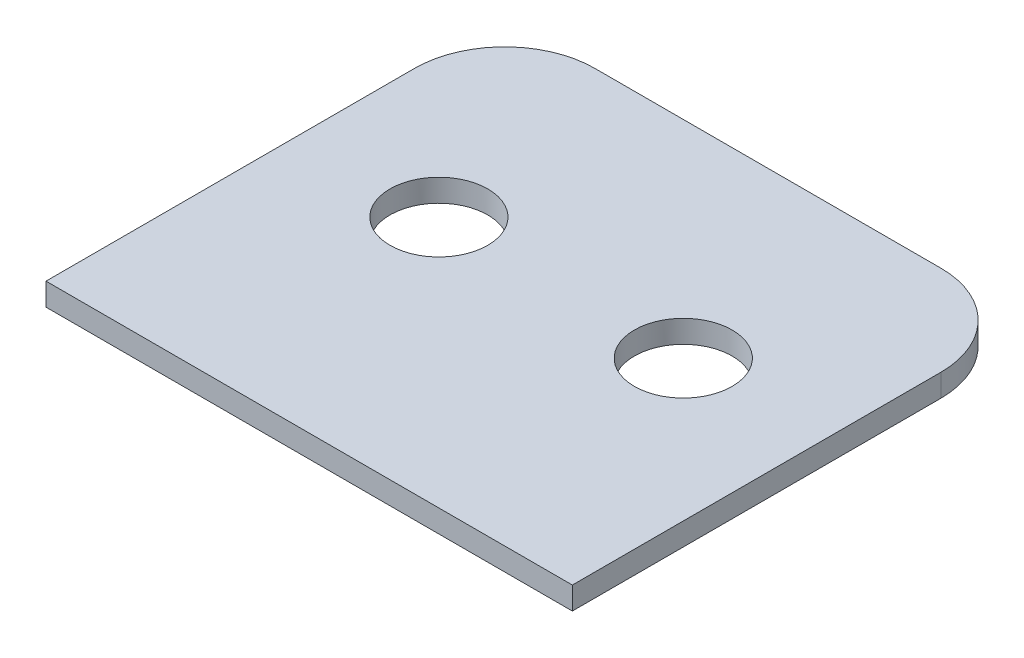
from build123d import *

# Parameters (mm, degrees)
SKETCH1_W               = 70
SKETCH1_H               = 67
BOSS_EXTRUDE1_DEPTH     = 3
SKETCH5_W               = 70
SKETCH5_H               = 6
CUT_EXTRUDE4_DEPTH      = 1
CUT_EXTRUDE4_DEPTH_BACK = 4
FILLET1_R               = 12
CUT_EXTRUDE1_START      = -4
SKETCH2_R               = 6.5
CUT_EXTRUDE1_DEPTH      = 5


with BuildPart() as part:
    # Sketch1 → Boss-Extrude1 (new body)
    with BuildSketch(Plane(origin=(0, 0, 0), x_dir=(1, 0, 0), z_dir=(0, 1, 0))):
        Rectangle(SKETCH1_W, SKETCH1_H)
    extrude(amount=BOSS_EXTRUDE1_DEPTH)

    # Sketch5 → Cut-Extrude4 (cut, two sides)
    with BuildSketch(Plane(origin=(0, 3, 0), x_dir=(1, 0, 0), z_dir=(0, 1, 0))) as cut_extrude4_sk:
        with Locations((0, 30.5)):
            Rectangle(SKETCH5_W, SKETCH5_H)
    extrude(amount=CUT_EXTRUDE4_DEPTH, mode=Mode.SUBTRACT)
    extrude(cut_extrude4_sk.sketch, amount=-CUT_EXTRUDE4_DEPTH_BACK, mode=Mode.SUBTRACT)

    # Fillet1
    fillet1_edges = [part.edges().sort_by_distance(p)[0] for p in [
        (-35, 1.5, -27.5),
        (35, 1.5, -27.5),
    ]]
    fillet(fillet1_edges, radius=FILLET1_R)

    # Sketch2 → Cut-Extrude1 (cut)
    with BuildSketch(Plane(origin=(0, 3, 0), x_dir=(1, 0, 0), z_dir=(0, 1, 0)).offset(CUT_EXTRUDE1_START)):
        with Locations((-16.25, 0)):
            Circle(SKETCH2_R)
    cut_extrude1 = extrude(amount=CUT_EXTRUDE1_DEPTH, mode=Mode.SUBTRACT)

    # Mirror1: Cut-Extrude1 across plane
    add(cut_extrude1.mirror(Plane(origin=(0, 0, 0), x_dir=(0, 0, 1), z_dir=(1, 0, 0))), mode=Mode.SUBTRACT)


solid = part.part
